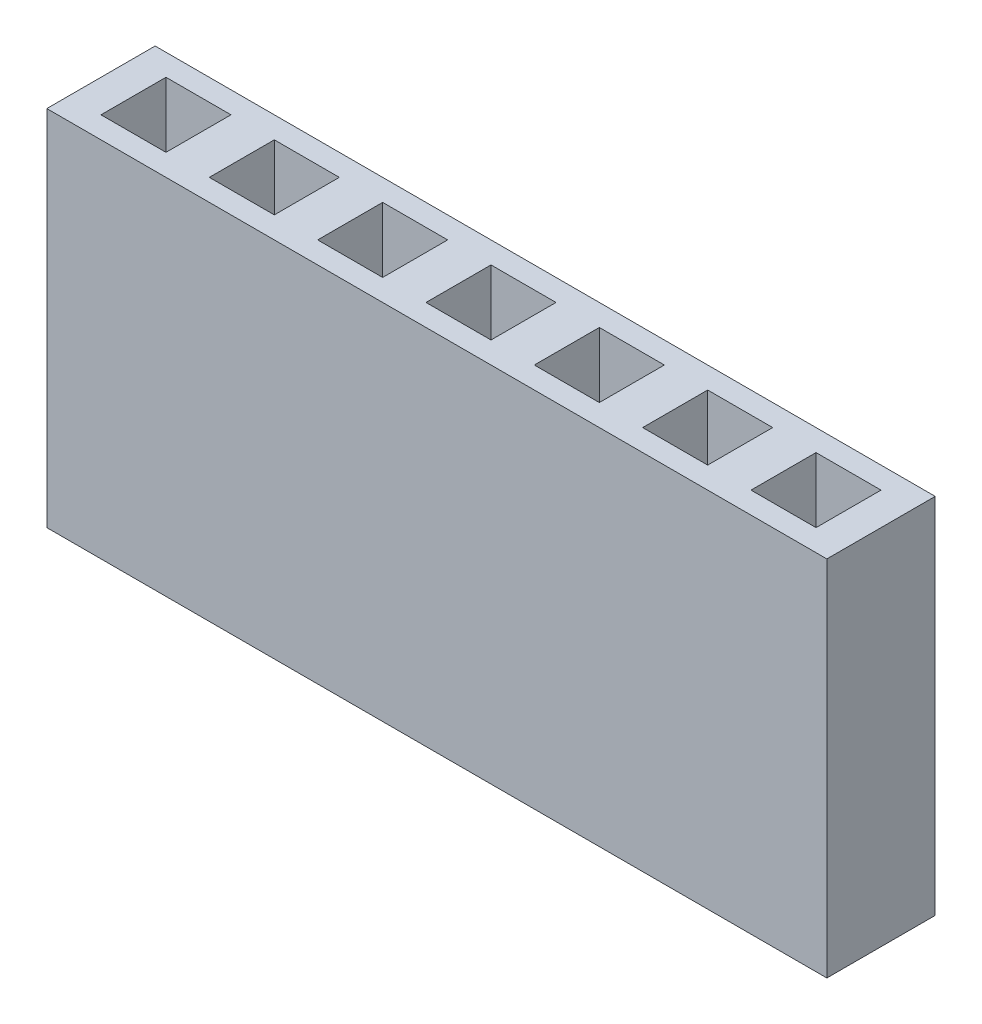
from build123d import *

# Parameters (mm, degrees)
SKETCH1_W           = 18.288
SKETCH1_H           = 2.54
BOSS_EXTRUDE1_DEPTH = 8.509
SKETCH2_W           = 1.524
SKETCH2_H           = 1.524
CUT_EXTRUDE1_DEPTH  = 5.9944


with BuildPart() as part:
    # Sketch1 → Boss-Extrude1 (new body)
    with BuildSketch(Plane(origin=(0, 0, 0), x_dir=(1, 0, 0), z_dir=(0, 1, 0))):
        Rectangle(SKETCH1_W, SKETCH1_H)
    extrude(amount=BOSS_EXTRUDE1_DEPTH)

    # Sketch2 → Cut-Extrude1 (cut)
    with BuildSketch(Plane(origin=(0, 8.509, 0), x_dir=(1, 0, 0), z_dir=(0, 1, 0))):
        with Locations((2.54, 0)):
            Rectangle(SKETCH2_W, SKETCH2_H)
        Rectangle(SKETCH2_W, SKETCH2_H)
        with Locations((5.08, 0)):
            Rectangle(SKETCH2_W, SKETCH2_H)
        with Locations((7.62, 0)):
            Rectangle(SKETCH2_W, SKETCH2_H)
        with Locations((-2.54, 0)):
            Rectangle(SKETCH2_W, SKETCH2_H)
        with Locations((-5.08, 0)):
            Rectangle(SKETCH2_W, SKETCH2_H)
        with Locations((-7.62, 0)):
            Rectangle(SKETCH2_W, SKETCH2_H)
    extrude(amount=-CUT_EXTRUDE1_DEPTH, mode=Mode.SUBTRACT)


solid = part.part
